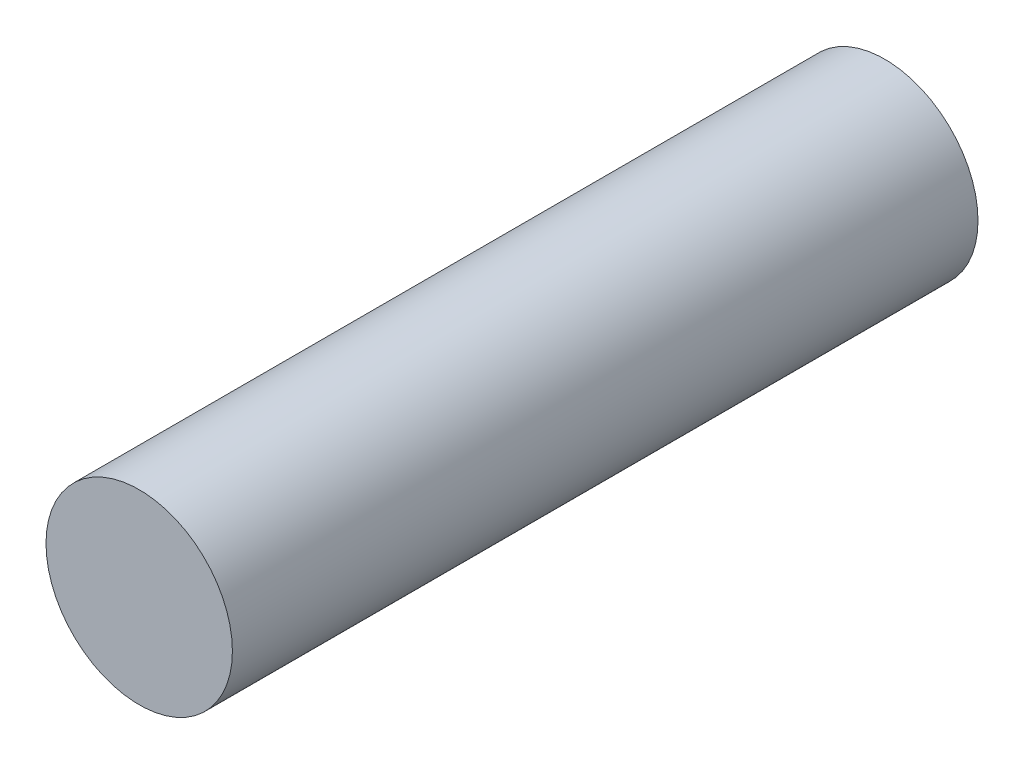
from build123d import *

# Parameters (mm, degrees)
CROQUIS2_R              = 10.5
SALIENTE_EXTRUIR1_DEPTH = 84


with BuildPart() as part:
    # Croquis2 → Saliente-Extruir1 (new body)
    with BuildSketch(Plane.XY):
        Circle(CROQUIS2_R)
    extrude(amount=SALIENTE_EXTRUIR1_DEPTH)


solid = part.part
